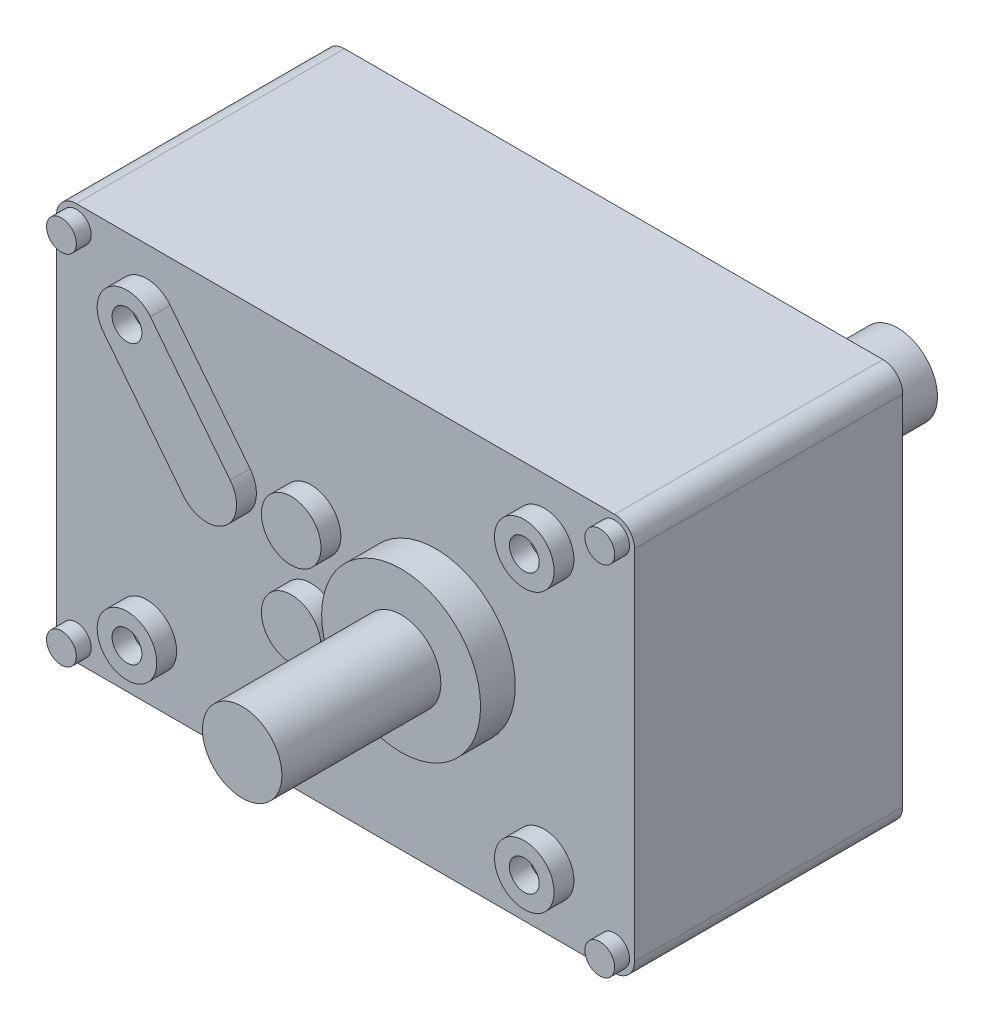
from build123d import *

# Parameters (mm, degrees)
SKETCH_1_W          = 58.2
SKETCH_1_H          = 40
EXTRUDE_1_DEPTH     = 13.5
SKETCH_2_R          = 8
EXTRUDE_2_DEPTH     = 3.5
SKETCH_4_R          = 4
EXTRUDE_3_DEPTH     = 19.5
SKETCH_5_R          = 1.5
SKETCH_5_R_2        = 3
EXTRUDE_4_DEPTH     = 2
SKETCH_6_R          = 1.5
EXTRUDE_5_DEPTH     = 1.5
FILLET_1_R          = 2
SKETCH_7_R          = 6.5
CUT_EXTRUDE_1_DEPTH = 15


with BuildPart() as part:
    # 草图1 → 凸台-拉伸1 (new body)
    with BuildSketch(Plane.XY):
        Rectangle(SKETCH_1_W, SKETCH_1_H)
    extrude_1 = extrude(amount=-EXTRUDE_1_DEPTH)

    # 草图2 → 凸台-拉伸2 (add)
    with BuildSketch(Plane.XY):
        with Locations((9.1, 0)):
            Circle(SKETCH_2_R)
    extrude_2 = extrude(amount=EXTRUDE_2_DEPTH)

    # 草图4 → 凸台-拉伸3 (add)
    with BuildSketch(Plane.XY):
        with Locations((9.1, 0)):
            Circle(SKETCH_4_R)
    extrude_3 = extrude(amount=EXTRUDE_3_DEPTH)

    # 草图5 → 凸台-拉伸4 (add)
    with BuildSketch(Plane.XY):
        with BuildLine():
            Line((-9.60900018, 5.631778998), (-17.641125745, 15.853567438))
            ThreePointArc((-17.641125745, 15.853567438), (-21.853567438, 16.358874255), (-22.358874255, 12.146432562))
            Line((-22.358874255, 12.146432562), (-14.32674869, 1.924644122))
            ThreePointArc((-14.32674869, 1.924644122), (-10.114306997, 1.419337305), (-9.60900018, 5.631778998))
        make_face()
        with Locations((-20, 14)):
            Circle(SKETCH_5_R, mode=Mode.SUBTRACT)
        with Locations((20, 14)):
            Circle(SKETCH_5_R_2)
        with Locations((20, 14)):
            Circle(SKETCH_5_R, mode=Mode.SUBTRACT)
        with Locations((20, -14)):
            Circle(SKETCH_5_R_2)
        with Locations((20, -14)):
            Circle(SKETCH_5_R, mode=Mode.SUBTRACT)
        with Locations((-3.467874435, 4.285302287)):
            Circle(SKETCH_5_R_2)
        with Locations((-20, -14)):
            Circle(SKETCH_5_R_2)
        with Locations((-20, -14)):
            Circle(SKETCH_5_R, mode=Mode.SUBTRACT)
        with Locations((-3.467874435, -4.285302287)):
            Circle(SKETCH_5_R_2)
    extrude_4 = extrude(amount=EXTRUDE_4_DEPTH)

    # 镜向2: 凸台-拉伸1, 凸台-拉伸2, 凸台-拉伸3, 凸台-拉伸4 across plane
    add(extrude_1.mirror(Plane(origin=(0, 0, -13.5), x_dir=(1, 0, 0), z_dir=(0, 0, -1))))
    add(extrude_2.mirror(Plane(origin=(0, 0, -13.5), x_dir=(1, 0, 0), z_dir=(0, 0, -1))))
    add(extrude_3.mirror(Plane(origin=(0, 0, -13.5), x_dir=(1, 0, 0), z_dir=(0, 0, -1))))
    add(extrude_4.mirror(Plane(origin=(0, 0, -13.5), x_dir=(1, 0, 0), z_dir=(0, 0, -1))))

    # 草图6 → 凸台-拉伸5 (add)
    with BuildSketch(Plane.XY):
        with Locations((27.1, 18)):
            Circle(SKETCH_6_R)
        with Locations((-27.1, 18)):
            Circle(SKETCH_6_R)
        with Locations((27.1, -18)):
            Circle(SKETCH_6_R)
        with Locations((-27.1, -18)):
            Circle(SKETCH_6_R)
    extrude(amount=EXTRUDE_5_DEPTH)

    # 圆角1
    fillet_1_edges = [part.edges().sort_by_distance(p)[0] for p in [
        (29.1, -20, -13.5),
        (-29.1, -20, -13.5),
        (-29.1, 20, -13.5),
        (29.1, 20, -13.5),
    ]]
    fillet(fillet_1_edges, radius=FILLET_1_R)

    # 草图7 → 切除-拉伸1 (cut)
    with BuildSketch(Plane.ZY.offset(29.1)):
        with Locations((-11.5, 2)):
            Circle(SKETCH_7_R)
    extrude(amount=-CUT_EXTRUDE_1_DEPTH, mode=Mode.SUBTRACT)


solid = part.part
